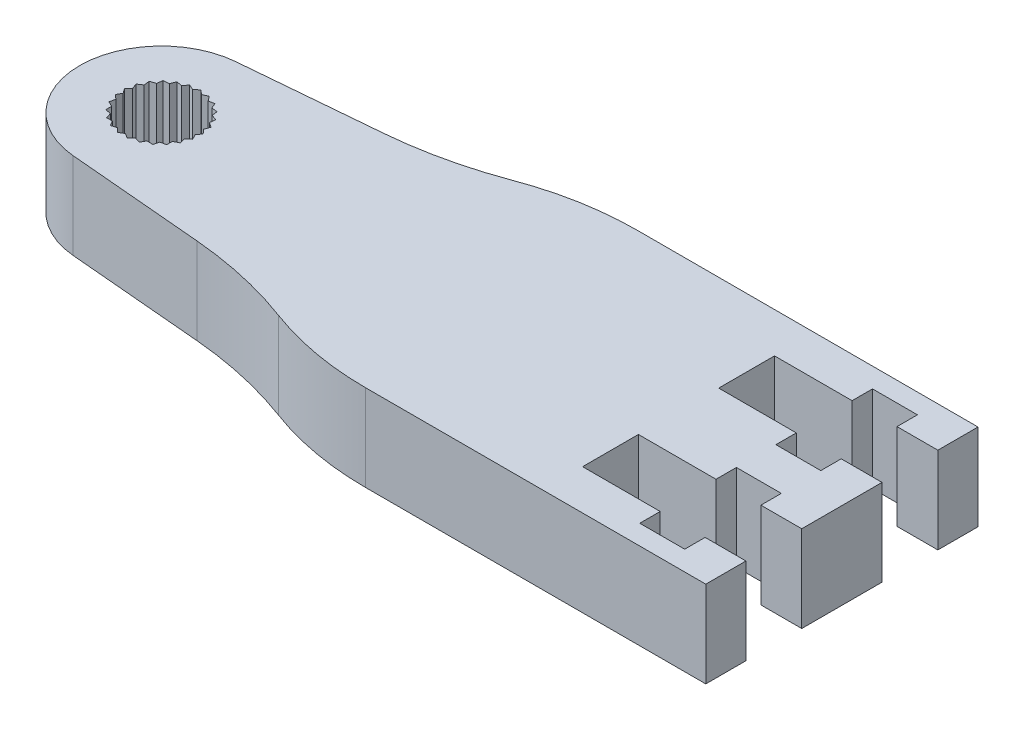
from build123d import *

# Parameters (mm, degrees)
BOSS_EXTRUDE1_DEPTH = 6.35


with BuildPart() as part:
    # Sketch1 → Boss-Extrude1 (new body)
    with BuildSketch(Plane(origin=(0, 0, 0), x_dir=(1, 0, 0), z_dir=(0, 1, 0))):
        with BuildLine():
            Line((50, -10), (50, -7.05))
            Line((50, -7.05), (47, -7.05))
            Line((47, -7.05), (47, -8.55))
            Line((47, -8.55), (43.7, -8.55))
            Line((43.7, -8.55), (43.7, -7.05))
            Line((43.7, -7.05), (38, -7.05))
            Line((38, -7.05), (38, -2.95))
            Line((38, -2.95), (43.7, -2.95))
            Line((43.7, -2.95), (43.7, -1.45))
            Line((43.7, -1.45), (47, -1.45))
            Line((47, -1.45), (47, -2.95))
            Line((47, -2.95), (50, -2.95))
            Line((50, -2.95), (50, 2.95))
            Line((50, 2.95), (47, 2.95))
            Line((47, 2.95), (47, 1.45))
            Line((47, 1.45), (43.7, 1.45))
            Line((43.7, 1.45), (43.7, 2.95))
            Line((43.7, 2.95), (38, 2.95))
            Line((38, 2.95), (38, 7.05))
            Line((38, 7.05), (43.7, 7.05))
            Line((43.7, 7.05), (43.7, 8.55))
            Line((43.7, 8.55), (47, 8.55))
            Line((47, 8.55), (47, 7.05))
            Line((47, 7.05), (50, 7.05))
            Line((50, 7.05), (50, 10))
            Line((50, 10), (25, 10))
            ThreePointArc((25, 10), (21.043842997, 9.646494123), (17.213036448, 8.59717729))
            ThreePointArc((17.213036448, 8.59717729), (13.403865442, 7.463896906), (9.477065544, 6.852054824))
            Line((9.477065544, 6.852054824), (-0.522934456, 5.977168189))
            ThreePointArc((-0.522934456, 5.977168189), (-6, 0), (-0.522934456, -5.977168189))
            Line((-0.522934456, -5.977168189), (9.477065544, -6.852054824))
            ThreePointArc((9.477065544, -6.852054824), (13.403865442, -7.463896906), (17.213036448, -8.59717729))
            ThreePointArc((17.213036448, -8.59717729), (21.043842997, -9.646494123), (25, -10))
            Line((25, -10), (50, -10))
        make_face()
        Polygon((0, 2.895), (-0.332133069, 2.629103958), (-0.719957223, 2.804048251), (-0.975530065, 2.463907688), (-1.394676887, 2.536907839), (-1.557630919, 2.143895035), (-1.981763872, 2.110364176), (-2.041860093, 1.689173573), (-2.444329344, 1.551218571), (-2.397791689, 1.128315123), (-2.753308615, 0.894604199), (-2.603061214, 0.496560484), (-2.889287379, 0.181778554), (-2.64477083, -0.166394877), (-2.843721591, -0.542468906), (-2.520299768, -0.818895035), (-2.619474317, -1.232631049), (-2.237469003, -1.419941007), (-2.230635838, -1.84534245), (-1.814049831, -1.931766863), (-1.701638305, -2.342104199), (-1.276647236, -2.322212702), (-1.06572058, -2.691702927), (-0.659028201, -2.566745377), (-0.362839711, -2.87217206), (0, -2.65), (0.362839711, -2.87217206), (0.659028201, -2.566745377), (1.06572058, -2.691702927), (1.276647236, -2.322212702), (1.701638305, -2.342104199), (1.814049831, -1.931766863), (2.230635838, -1.84534245), (2.237469003, -1.419941007), (2.619474317, -1.232631049), (2.520299768, -0.818895035), (2.843721591, -0.542468906), (2.64477083, -0.166394877), (2.889287379, 0.181778554), (2.603061214, 0.496560484), (2.753308615, 0.894604199), (2.397791689, 1.128315123), (2.444329344, 1.551218571), (2.041860093, 1.689173573), (1.981763872, 2.110364176), (1.557630919, 2.143895035), (1.394676887, 2.536907839), (0.975530065, 2.463907688), (0.719957223, 2.804048251), (0.332133069, 2.629103958), align=None, mode=Mode.SUBTRACT)
    extrude(amount=BOSS_EXTRUDE1_DEPTH)


solid = part.part
